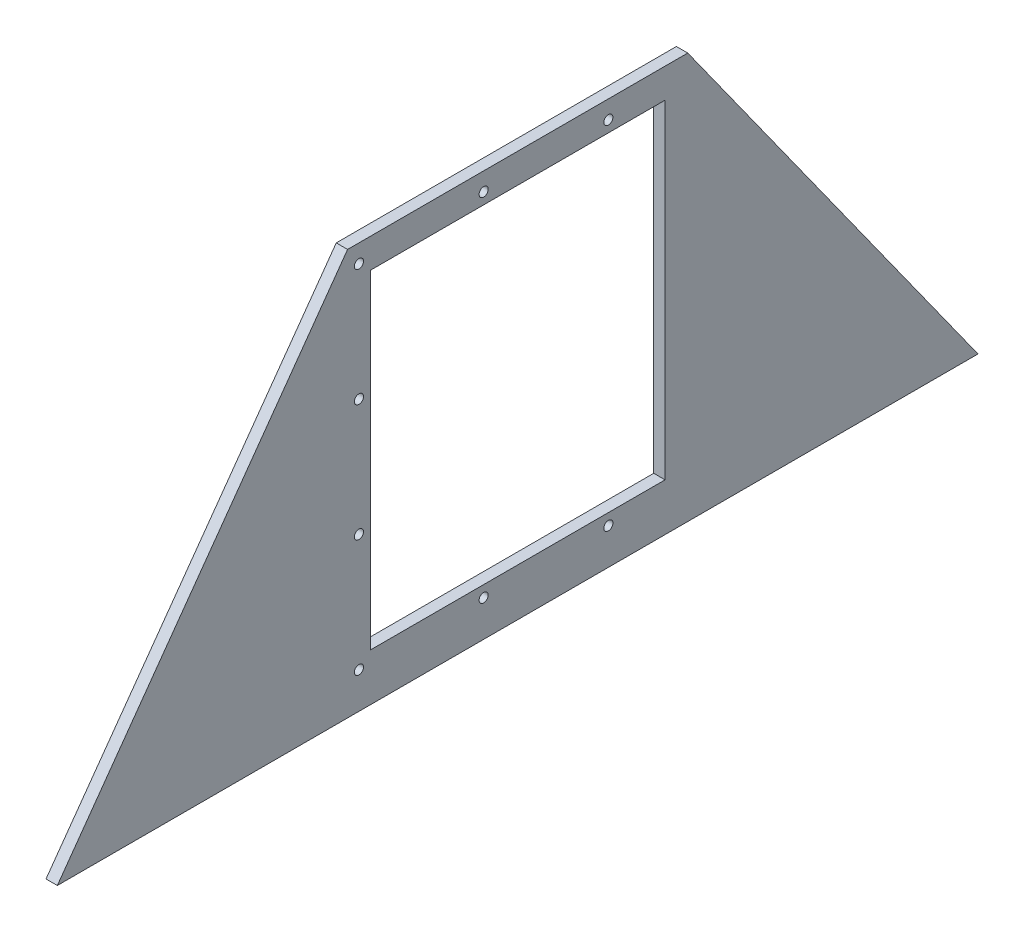
from build123d import *

# Parameters (mm, degrees)
BOSS_EXTRUDE1_DEPTH         = 6.35
SKETCH3_W                   = 165.1
SKETCH3_H                   = 184.15
CUT_EXTRUDE1_DEPTH          = 7.35
F_1_4_CLEARANCE_HOLE1_D     = 5.1054
F_1_4_CLEARANCE_HOLE1_DEPTH = 25.4
F_1_4_CLEARANCE_HOLE1_TIP   = 1.533816902


with BuildPart() as part:
    # Sketch1 → Boss-Extrude1 (new body)
    with BuildSketch(Plane(origin=(0, 0, 0), x_dir=(0, 0, -1), z_dir=(1, 0, 0))):
        Polygon((257.81, 0), (-257.81, 0), (-95.25, 227.241295543), (95.25, 227.241295543), align=None)
    extrude(amount=BOSS_EXTRUDE1_DEPTH)

    # Sketch3 → Cut-Extrude1 (cut, through all)
    with BuildSketch(Plane(origin=(6.35, 0, 0), x_dir=(0, 0, -1), z_dir=(1, 0, 0))):
        with Locations((0, 118.656295543)):
            Rectangle(SKETCH3_W, SKETCH3_H)
    extrude(amount=-CUT_EXTRUDE1_DEPTH, mode=Mode.SUBTRACT)

    # 1/4 Clearance Hole1
    with Locations(Plane.ZY):
        with Locations((19.05, 217.081295543), (-50.8, 217.081295543), (-50.8, 151.464628876), (-50.8, 85.84796221), (-50.8, 20.231295543), (19.05, 20.231295543), (88.9, 20.231295543), (88.9, 85.84796221), (88.9, 151.464628876), (88.9, 217.081295543)):
            Hole(F_1_4_CLEARANCE_HOLE1_D / 2, depth=F_1_4_CLEARANCE_HOLE1_DEPTH)
            with Locations((0, 0, -(F_1_4_CLEARANCE_HOLE1_DEPTH + F_1_4_CLEARANCE_HOLE1_TIP / 2))):  # 118° drill point
                Cone(0, F_1_4_CLEARANCE_HOLE1_D / 2, F_1_4_CLEARANCE_HOLE1_TIP, mode=Mode.SUBTRACT)


solid = part.part
